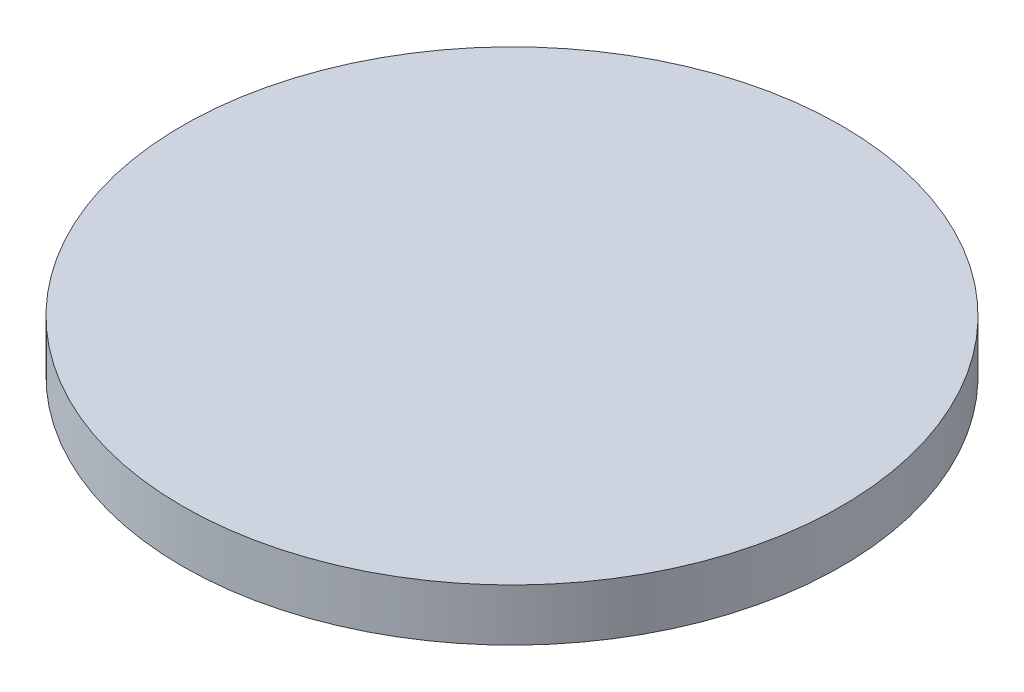
from build123d import *

# Parameters (mm, degrees)
SKETCH1_R           = 13.915
BOSS_EXTRUDE1_DEPTH = 2.2


with BuildPart() as part:
    # Sketch1 → Boss-Extrude1 (new body)
    with BuildSketch(Plane(origin=(0, 0, 0), x_dir=(1, 0, 0), z_dir=(0, 1, 0))):
        Circle(SKETCH1_R)
    extrude(amount=BOSS_EXTRUDE1_DEPTH)


solid = part.part
